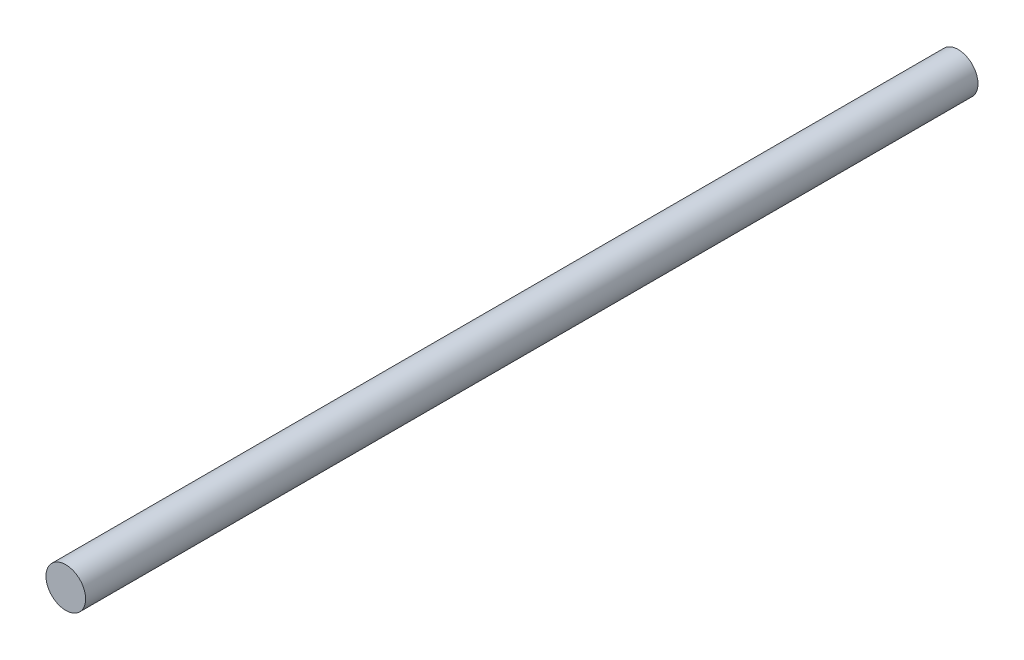
from build123d import *

# Parameters (mm, degrees)
SKETCH_1_R      = 2
EXTRUDE_1_DEPTH = 90


with BuildPart() as part:
    # 草图1 → 凸台-拉伸1 (new body)
    with BuildSketch(Plane.XY):
        Circle(SKETCH_1_R)
    extrude(amount=EXTRUDE_1_DEPTH)


solid = part.part
